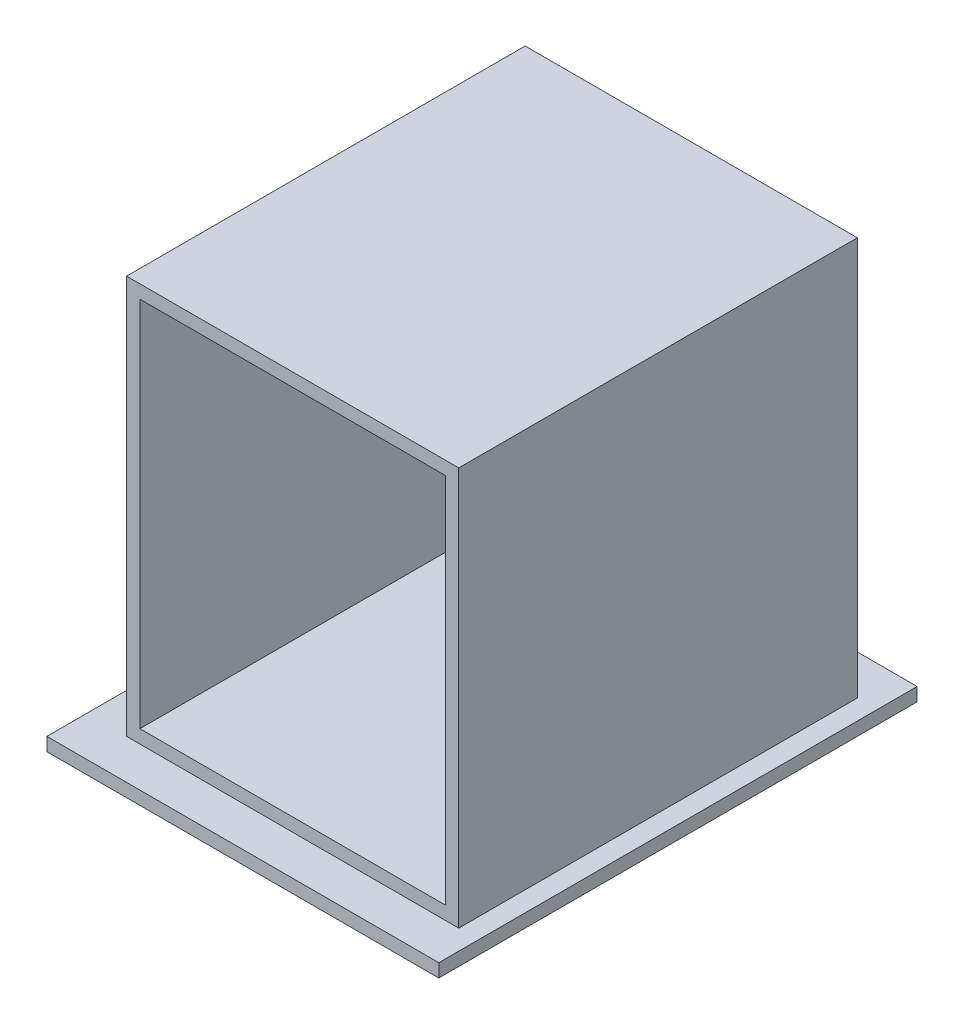
from build123d import *

# Parameters (mm, degrees)
SKETCH_1_W          = 250
SKETCH_1_H          = 300
EXTRUDE_1_DEPTH     = 300
SKETCH_2_W          = 230
SKETCH_2_H          = 280
CUT_EXTRUDE_1_DEPTH = 290
SKETCH_3_W          = 295
SKETCH_3_H          = 360
EXTRUDE_2_DEPTH     = 10
CUT_EXTRUDE_2_DEPTH = 15


with BuildPart() as part:
    # 草图1 → 凸台-拉伸1 (new body)
    with BuildSketch(Plane.XY):
        with Locations((125, 150)):
            Rectangle(SKETCH_1_W, SKETCH_1_H)
    extrude(amount=EXTRUDE_1_DEPTH)

    # 草图2 → 切除-拉伸1 (cut)
    with BuildSketch(Plane.XY.offset(300)):
        with Locations((125, 150)):
            Rectangle(SKETCH_2_W, SKETCH_2_H)
    extrude(amount=-CUT_EXTRUDE_1_DEPTH, mode=Mode.SUBTRACT)

    # 草图3 → 凸台-拉伸2 (add)
    with BuildSketch(Plane.XZ):
        with Locations((117.5, 150)):
            Rectangle(SKETCH_3_W, SKETCH_3_H)
    extrude(amount=EXTRUDE_2_DEPTH)

    # 草图4 → 切除-拉伸2 (cut)
    with BuildSketch(Plane.XZ.offset(10)):
        with BuildLine():
            Line((75.410884938, 284.219295629), (151.62630951, 284.219295629))
            ThreePointArc((151.62630951, 284.219295629), (165.845605139, 270), (151.62630951, 255.780704371))
            Line((151.62630951, 255.780704371), (75.410884938, 255.780704371))
            ThreePointArc((75.410884938, 255.780704371), (61.191589309, 270), (75.410884938, 284.219295629))
        make_face()
    extrude(amount=-CUT_EXTRUDE_2_DEPTH, mode=Mode.SUBTRACT)


solid = part.part
